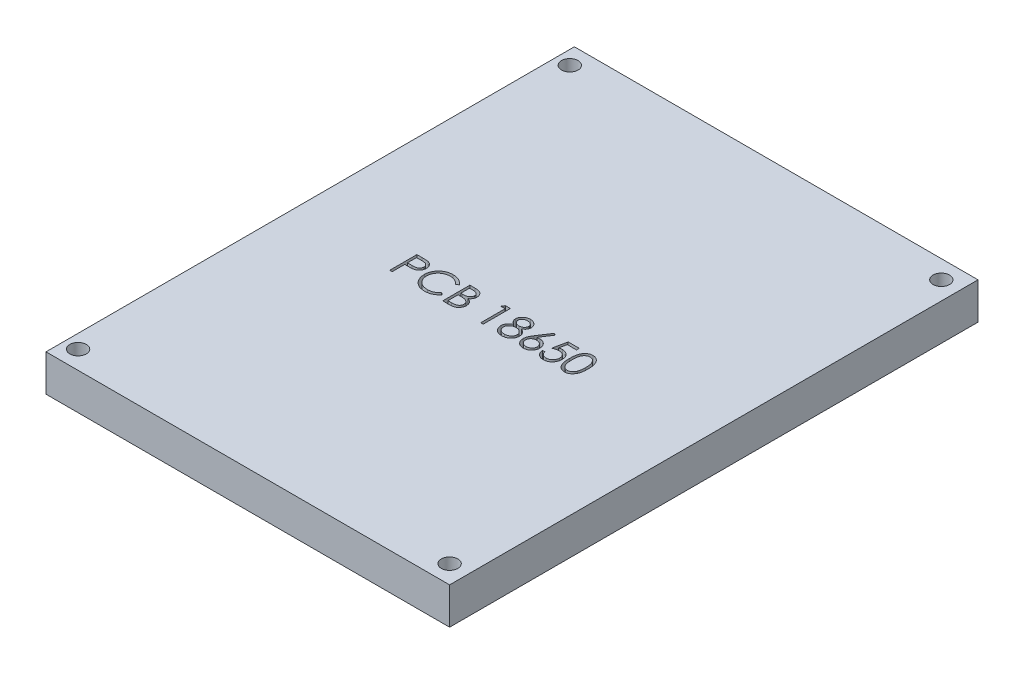
from build123d import *

# Parameters (mm, degrees)
CROQUIS1_W              = 110
CROQUIS1_H              = 144
SALIENTE_EXTRUIR1_DEPTH = 10
CORTAR_EXTRUIR1_DEPTH   = 3
CROQUIS3_R              = 2.25
CORTAR_EXTRUIR2_DEPTH   = 10


with BuildPart() as part:
    # Croquis1 → Saliente-Extruir1 (new body)
    with BuildSketch(Plane(origin=(0, 0, 0), x_dir=(1, 0, 0), z_dir=(0, 1, 0))):
        with Locations((-8.912037037, -15.981481481)):
            Rectangle(CROQUIS1_W, CROQUIS1_H)
    extrude(amount=SALIENTE_EXTRUIR1_DEPTH)

    # Croquis2 → Cortar-Extruir1 (cut)
    with BuildSketch(Plane(origin=(0, 10, 0), x_dir=(1, 0, 0), z_dir=(0, 1, 0))):
        with BuildLine():
            Line((-36.322498936, -14.485321481), (-34.869622667, -14.485321481))
            add(Edge.make_bspline(
                [(-34.869622667, -14.485321481), (-34.769692916, -14.485431328), (-34.578223074, -14.4856418), (-34.30365954, -14.492023012), (-34.054295608, -14.500546177), (-33.830668968, -14.512361184), (-33.632091561, -14.526323967), (-33.459461943, -14.54590745), (-33.311423216, -14.566355076), (-33.222721231, -14.587143719), (-33.1822679, -14.596624566)],
                knots=[0, 0, 0, 0, 0.00029978, 0.000574392, 0.00082387, 0.001048274, 0.001246209, 0.00142091, 0.001569507, 0.001694096, 0.001694096, 0.001694096, 0.001694096], degree=3))
            add(Edge.make_bspline(
                [(-33.1822679, -14.596624566), (-33.131058253, -14.610641026), (-33.029845651, -14.638343667), (-32.88400511, -14.693829382), (-32.745249471, -14.759619965), (-32.613102672, -14.834600637), (-32.489188596, -14.921988415), (-32.371658476, -15.018240906), (-32.261549518, -15.125580392), (-32.159480905, -15.242802958), (-32.06574475, -15.367940736), (-31.985036922, -15.502861789), (-31.917457624, -15.645295048), (-31.859496366, -15.795141441), (-31.817780138, -15.953659292), (-31.7863542, -16.119747166), (-31.766407522, -16.293387261), (-31.764497099, -16.412047314), (-31.763524577, -16.472452557)],
                knots=[0, 0, 0, 0, 0.000159208, 0.000314664, 0.000467348, 0.000619576, 0.000769845, 0.000921668, 0.001074891, 0.001230553, 0.001387567, 0.001543328, 0.001701307, 0.001860064, 0.002024586, 0.002192236, 0.002366938, 0.002548088, 0.002548088, 0.002548088, 0.002548088], degree=3))
            add(Edge.make_bspline(
                [(-31.763524577, -16.472452557), (-31.764416593, -16.533365518), (-31.766161882, -16.65254584), (-31.787109019, -16.826901575), (-31.815324591, -16.993522168), (-31.858710019, -17.152038171), (-31.91553336, -17.301508219), (-31.982191538, -17.444216493), (-32.062590011, -17.577735132), (-32.154971567, -17.702548864), (-32.257739109, -17.818774845), (-32.370457828, -17.925570827), (-32.492672664, -18.022311676), (-32.62399521, -18.109214271), (-32.765705724, -18.184263395), (-32.915654949, -18.251483024), (-33.07514624, -18.307936769), (-33.185514562, -18.337633733), (-33.241629545, -18.352732672)],
                knots=[0, 0, 0, 0, 0.000182634, 0.000357335, 0.000526177, 0.000689266, 0.000849412, 0.001005413, 0.001161174, 0.001316112, 0.001470659, 0.001626023, 0.00178131, 0.001937719, 0.002097735, 0.002261827, 0.002430336, 0.002604627, 0.002604627, 0.002604627, 0.002604627], degree=3))
            add(Edge.make_bspline(
                [(-33.241629545, -18.352732672), (-33.288042402, -18.362602649), (-33.389758876, -18.384233276), (-33.557277638, -18.408381177), (-33.752318705, -18.428992431), (-33.974615864, -18.444446506), (-34.22396958, -18.457676453), (-34.500514741, -18.468192251), (-34.804794205, -18.473970442), (-35.017035005, -18.474268453), (-35.127845824, -18.474424045)],
                knots=[0, 0, 0, 0, 0.000142321, 0.000311905, 0.000507421, 0.000730625, 0.000980302, 0.001256529, 0.001560815, 0.001893243, 0.001893243, 0.001893243, 0.001893243], degree=3))
            Line((-35.127845824, -18.474424045), (-35.657648509, -18.474424045))
            Line((-35.657648509, -18.474424045), (-35.657648509, -21.893654814))
            Line((-35.657648509, -21.893654814), (-36.322498936, -21.893654814))
            Line((-36.322498936, -21.893654814), (-36.322498936, -14.485321481))
        make_face()
        with BuildLine():
            Line((-35.657648509, -15.245150541), (-35.657648509, -17.714594985))
            Line((-35.657648509, -17.714594985), (-34.360596559, -17.730919438))
            add(Edge.make_bspline(
                [(-34.360596559, -17.730919438), (-34.297266049, -17.730952169), (-34.175007806, -17.731015356), (-33.998401134, -17.722579966), (-33.834551475, -17.712842172), (-33.683962124, -17.698584467), (-33.546565196, -17.678431139), (-33.422131593, -17.658086294), (-33.311626178, -17.628653276), (-33.182299534, -17.58902278), (-33.038189782, -17.521432077), (-32.881413471, -17.42332481), (-32.748549063, -17.298270644), (-32.633575335, -17.157665068), (-32.54233456, -17.001245244), (-32.475541043, -16.833882661), (-32.436295593, -16.657293713), (-32.43103315, -16.536457152), (-32.428375004, -16.47542064)],
                knots=[0, 0, 0, 0, 0.000189963, 0.00036672, 0.000530295, 0.000682392, 0.000820281, 0.000946912, 0.001060293, 0.001163078, 0.001352344, 0.00153594, 0.001715534, 0.001897012, 0.002079253, 0.002256452, 0.002435769, 0.002618794, 0.002618794, 0.002618794, 0.002618794], degree=3))
            add(Edge.make_bspline(
                [(-32.428375004, -16.47542064), (-32.431047606, -16.415860786), (-32.436360408, -16.297463169), (-32.475848651, -16.123941459), (-32.542204699, -15.958342551), (-32.634187824, -15.803882854), (-32.745823216, -15.663783219), (-32.875573492, -15.542080967), (-33.023133229, -15.444245029), (-33.160395318, -15.381097916), (-33.282317828, -15.34254225), (-33.38821881, -15.315565671), (-33.507790737, -15.294027304), (-33.641072537, -15.276587024), (-33.787031169, -15.261657197), (-33.946920602, -15.251526879), (-34.120135147, -15.24559713), (-34.240384189, -15.245303008), (-34.302718955, -15.245150541)],
                knots=[0, 0, 0, 0, 0.000178585, 0.000355005, 0.000530825, 0.000711787, 0.000892334, 0.001066644, 0.00124322, 0.001421188, 0.001517867, 0.001626567, 0.001748818, 0.001882093, 0.002029761, 0.002188893, 0.002362627, 0.002549622, 0.002549622, 0.002549622, 0.002549622], degree=3))
            Line((-34.302718955, -15.245150541), (-35.657648509, -15.245150541))
        make_face(mode=Mode.SUBTRACT)
        with BuildLine():
            Line((-23.405404919, -15.844703158), (-23.987149043, -16.289915498))
            add(Edge.make_bspline(
                [(-23.987149043, -16.289915498), (-24.028648173, -16.240457529), (-24.111086936, -16.14220839), (-24.243715581, -16.004245021), (-24.381937392, -15.874990218), (-24.525699532, -15.753828239), (-24.677589668, -15.644996085), (-24.833928358, -15.542822251), (-24.997330887, -15.451238872), (-25.223288726, -15.340192218), (-25.518876671, -15.224312856), (-25.890975747, -15.127151017), (-26.279407572, -15.065299528), (-26.544409158, -15.058600614), (-26.679199657, -15.055193276)],
                knots=[0, 0, 0, 0, 0.000193643, 0.000384676, 0.000573668, 0.00076121, 0.000948223, 0.00113387, 0.00132126, 0.00150975, 0.00188896, 0.002271247, 0.002661637, 0.003065757, 0.003065757, 0.003065757, 0.003065757], degree=3))
            add(Edge.make_bspline(
                [(-26.679199657, -15.055193276), (-26.753459307, -15.05604833), (-26.901289408, -15.057750502), (-27.120678677, -15.080206484), (-27.335971302, -15.111768545), (-27.547027239, -15.158600479), (-27.753577835, -15.217809189), (-27.956973419, -15.288559649), (-28.154269189, -15.37609406), (-28.348194459, -15.47284321), (-28.533993789, -15.582121302), (-28.70979364, -15.701317896), (-28.874952839, -15.829099151), (-29.029602035, -15.965943992), (-29.173899326, -16.111236142), (-29.306799133, -16.266523998), (-29.427841585, -16.431311099), (-29.539425955, -16.603424478), (-29.639359574, -16.782362804), (-29.723031152, -16.96878837), (-29.797125327, -17.159508721), (-29.855755391, -17.356678678), (-29.902162285, -17.558910866), (-29.934182505, -17.766748034), (-29.956383103, -17.979755989), (-29.95807681, -18.124132367), (-29.95893056, -18.196908353)],
                knots=[0, 0, 0, 0, 0.000222685, 0.000443304, 0.000660953, 0.0008752, 0.00109128, 0.001305311, 0.00152064, 0.001738329, 0.001955182, 0.002166751, 0.002375136, 0.002581198, 0.002785829, 0.002988969, 0.003193773, 0.003398769, 0.003604029, 0.00380791, 0.00401131, 0.004217421, 0.004424428, 0.004633277, 0.004847987, 0.005066222, 0.005066222, 0.005066222, 0.005066222], degree=3))
            add(Edge.make_bspline(
                [(-29.95893056, -18.196908353), (-29.95625971, -18.306406314), (-29.951015849, -18.521391035), (-29.904346876, -18.836288827), (-29.833427766, -19.137957587), (-29.727138128, -19.424511586), (-29.596076138, -19.699484278), (-29.430466843, -19.958223184), (-29.238661839, -20.204638246), (-29.017947651, -20.432905818), (-28.775788674, -20.641426537), (-28.515972261, -20.825048601), (-28.239145519, -20.978115102), (-27.948364985, -21.105487522), (-27.641393044, -21.203397596), (-27.318781712, -21.272324991), (-26.981232655, -21.317287606), (-26.750580759, -21.321592246), (-26.633194382, -21.323783019)],
                knots=[0, 0, 0, 0, 0.000328309, 0.000644591, 0.000953061, 0.001256343, 0.001559672, 0.001865168, 0.002175989, 0.002495062, 0.00281603, 0.003133469, 0.0034477, 0.003763386, 0.004084406, 0.00441246, 0.004752075, 0.005104046, 0.005104046, 0.005104046, 0.005104046], degree=3))
            add(Edge.make_bspline(
                [(-26.633194382, -21.323783019), (-26.503860357, -21.320208436), (-26.249300056, -21.3131728), (-25.875987734, -21.253569056), (-25.518618697, -21.156926463), (-25.177173722, -21.021675861), (-24.852615387, -20.845854334), (-24.54443579, -20.632710494), (-24.252374799, -20.380216856), (-24.076752252, -20.187424235), (-23.987149043, -20.089060797)],
                knots=[0, 0, 0, 0, 0.000387815, 0.000763313, 0.001130882, 0.001496577, 0.00186244, 0.002235811, 0.002618757, 0.003017658, 0.003017658, 0.003017658, 0.003017658], degree=3))
            Line((-23.987149043, -20.089060797), (-23.405404919, -20.529821013))
            add(Edge.make_bspline(
                [(-23.405404919, -20.529821013), (-23.452221585, -20.590227403), (-23.545630667, -20.71075084), (-23.69688347, -20.880659292), (-23.856220416, -21.040476167), (-24.024825002, -21.188912966), (-24.200757661, -21.328939918), (-24.387177389, -21.456578794), (-24.581633508, -21.573611166), (-24.783467155, -21.680771489), (-24.992463885, -21.775846329), (-25.208373273, -21.857240137), (-25.430264657, -21.927354487), (-25.658148184, -21.985037753), (-25.892496536, -22.030061547), (-26.132464039, -22.060159859), (-26.378568608, -22.080780244), (-26.54460295, -22.082659666), (-26.628742259, -22.083612079)],
                knots=[0, 0, 0, 0, 0.000229221, 0.000457343, 0.00068191, 0.000905843, 0.001130894, 0.001356063, 0.001583087, 0.001811456, 0.002041252, 0.002271398, 0.002503261, 0.002739018, 0.002976228, 0.003218654, 0.003464279, 0.003716636, 0.003716636, 0.003716636, 0.003716636], degree=3))
            add(Edge.make_bspline(
                [(-26.628742259, -22.083612079), (-26.708421354, -22.083057528), (-26.865976898, -22.081960973), (-27.098595922, -22.064197552), (-27.325057202, -22.039962275), (-27.544713493, -22.003470664), (-27.758763473, -21.960408478), (-27.965266711, -21.902684318), (-28.166255239, -21.838021915), (-28.36092156, -21.762023027), (-28.549431258, -21.676263774), (-28.731176326, -21.579338307), (-28.906073174, -21.472061694), (-29.075841315, -21.356798588), (-29.237972867, -21.229846633), (-29.393872829, -21.092968923), (-29.544415404, -20.9466268), (-29.63755442, -20.841100694), (-29.68438295, -20.788044171)],
                knots=[0, 0, 0, 0, 0.000238972, 0.000472538, 0.000699518, 0.000922026, 0.001140316, 0.001354167, 0.001564885, 0.001773508, 0.001980706, 0.002185853, 0.002390994, 0.002595985, 0.002801116, 0.003008293, 0.003218178, 0.003430412, 0.003430412, 0.003430412, 0.003430412], degree=3))
            add(Edge.make_bspline(
                [(-29.68438295, -20.788044171), (-29.759388396, -20.695881987), (-29.908493755, -20.512670284), (-30.099259785, -20.215731623), (-30.262555444, -19.905707248), (-30.394584476, -19.580968399), (-30.497798928, -19.242243762), (-30.569302458, -18.88936259), (-30.615766687, -18.522654446), (-30.621080132, -18.273233243), (-30.623780987, -18.146450955)],
                knots=[0, 0, 0, 0, 0.000356247, 0.000708193, 0.00105669, 0.001406134, 0.00175823, 0.002117387, 0.002485166, 0.00286537, 0.00286537, 0.00286537, 0.00286537], degree=3))
            add(Edge.make_bspline(
                [(-30.623780987, -18.146450955), (-30.620489161, -18.013195245), (-30.614012698, -17.751022954), (-30.558988264, -17.366268087), (-30.470471812, -16.997647626), (-30.344748398, -16.6458497), (-30.185352071, -16.30902394), (-29.988445739, -15.98974339), (-29.756316954, -15.685966164), (-29.490786269, -15.402301607), (-29.199602076, -15.142926644), (-28.887777254, -14.914736846), (-28.555922132, -14.72483477), (-28.20769268, -14.566092893), (-27.84048132, -14.444078779), (-27.455071522, -14.358664534), (-27.052187486, -14.305499971), (-26.777312019, -14.298779115), (-26.637646505, -14.295364216)],
                knots=[0, 0, 0, 0, 0.000399604, 0.000786196, 0.001163414, 0.001535172, 0.001904915, 0.00227932, 0.002658359, 0.003050013, 0.003443158, 0.003826676, 0.004206973, 0.004588207, 0.004973029, 0.005365467, 0.005770983, 0.006189861, 0.006189861, 0.006189861, 0.006189861], degree=3))
            add(Edge.make_bspline(
                [(-26.637646505, -14.295364216), (-26.552525873, -14.296384742), (-26.384038154, -14.29840477), (-26.13479504, -14.318102771), (-25.892135448, -14.350939904), (-25.655892202, -14.395635585), (-25.424915998, -14.451107749), (-25.200972155, -14.52337138), (-24.982746601, -14.605998705), (-24.771615645, -14.701160791), (-24.568592281, -14.80798206), (-24.37373974, -14.925278464), (-24.188605789, -15.052904585), (-24.011887726, -15.189774973), (-23.846541746, -15.338785257), (-23.687873283, -15.495836835), (-23.541270668, -15.66545343), (-23.450776405, -15.784843873), (-23.405404919, -15.844703158)],
                knots=[0, 0, 0, 0, 0.000255324, 0.000505388, 0.00074948, 0.000989606, 0.001226445, 0.001461584, 0.001695032, 0.001926181, 0.002155862, 0.002382886, 0.002608055, 0.002830107, 0.00305293, 0.003275398, 0.003499469, 0.003724774, 0.003724774, 0.003724774, 0.003724774], degree=3))
        make_face()
        with BuildLine():
            Line((-21.885746799, -14.485321481), (-20.440290736, -14.485321481))
            add(Edge.make_bspline(
                [(-20.440290736, -14.485321481), (-20.369533791, -14.485693486), (-20.23238922, -14.486414524), (-20.032958069, -14.497597152), (-19.846164753, -14.51284492), (-19.671955101, -14.537038616), (-19.510409615, -14.566231211), (-19.361041449, -14.601583388), (-19.224325584, -14.643973054), (-19.061103626, -14.711381016), (-18.875004894, -14.811548389), (-18.673501629, -14.959563852), (-18.501195989, -15.140607565), (-18.352634951, -15.344829186), (-18.234522581, -15.569483236), (-18.149074235, -15.809215186), (-18.094976732, -16.060932873), (-18.089413213, -16.233744266), (-18.0866015, -16.321080362)],
                knots=[0, 0, 0, 0, 0.000212239, 0.000411371, 0.000599072, 0.000774321, 0.000938782, 0.0010914, 0.001234554, 0.001367664, 0.001620652, 0.001866708, 0.002114396, 0.002367311, 0.002622221, 0.002872887, 0.003129012, 0.003390713, 0.003390713, 0.003390713, 0.003390713], degree=3))
            add(Edge.make_bspline(
                [(-18.0866015, -16.321080362), (-18.088915479, -16.402894938), (-18.093462666, -16.563668296), (-18.13694484, -16.798817494), (-18.205018255, -17.022657573), (-18.299644366, -17.234371623), (-18.422626924, -17.429176104), (-18.568377032, -17.608642484), (-18.744222931, -17.765172221), (-18.875971122, -17.852681365), (-18.942893234, -17.897132044)],
                knots=[0, 0, 0, 0, 0.000245231, 0.000481902, 0.00071474, 0.000945889, 0.001175244, 0.001404022, 0.001637324, 0.001878168, 0.001878168, 0.001878168, 0.001878168], degree=3))
            add(Edge.make_bspline(
                [(-18.942893234, -17.897132044), (-18.858733662, -17.929442959), (-18.697715553, -17.991261742), (-18.47613016, -18.100556808), (-18.285217738, -18.219433275), (-18.123510446, -18.349252357), (-17.98521241, -18.489182674), (-17.86445035, -18.641275999), (-17.761408108, -18.80751637), (-17.673115753, -18.986170519), (-17.604220886, -19.175414211), (-17.552625222, -19.373472354), (-17.523060788, -19.579634745), (-17.518853614, -19.719938798), (-17.516729705, -19.79076853)],
                knots=[0, 0, 0, 0, 0.000270344, 0.000517235, 0.000739985, 0.00094371, 0.001137847, 0.001329058, 0.001525064, 0.00172351, 0.001925868, 0.002128155, 0.002336561, 0.002549033, 0.002549033, 0.002549033, 0.002549033], degree=3))
            add(Edge.make_bspline(
                [(-17.516729705, -19.79076853), (-17.518797363, -19.863088409), (-17.522865537, -20.005379797), (-17.55287981, -20.214411499), (-17.603699087, -20.414171803), (-17.67369968, -20.605952773), (-17.765059912, -20.789383391), (-17.876244103, -20.964671466), (-18.008814246, -21.130055799), (-18.157113986, -21.287374135), (-18.324885527, -21.428826285), (-18.505893875, -21.554801197), (-18.702418585, -21.658403695), (-18.911231973, -21.745432607), (-19.134676442, -21.811911178), (-19.371748627, -21.858419792), (-19.622244066, -21.889757121), (-19.79413804, -21.892333538), (-19.88229127, -21.893654814)],
                knots=[0, 0, 0, 0, 0.000216919, 0.000426794, 0.000631957, 0.000834315, 0.001038067, 0.001245562, 0.001455778, 0.001673062, 0.001893106, 0.002112925, 0.002333348, 0.002558238, 0.002790646, 0.00303134, 0.003282419, 0.003546729, 0.003546729, 0.003546729, 0.003546729], degree=3))
            Line((-19.88229127, -21.893654814), (-21.885746799, -21.893654814))
            Line((-21.885746799, -21.893654814), (-21.885746799, -14.485321481))
        make_face()
        with BuildLine():
            Line((-21.220896372, -15.245150541), (-21.220896372, -17.619616353))
            Line((-21.220896372, -17.619616353), (-20.774199991, -17.619616353))
            add(Edge.make_bspline(
                [(-20.774199991, -17.619616353), (-20.708903374, -17.618769849), (-20.582737004, -17.617134231), (-20.400026556, -17.612448954), (-20.230428601, -17.599329762), (-20.074235887, -17.58621434), (-19.931694381, -17.564889796), (-19.803119874, -17.53950647), (-19.686494511, -17.512660987), (-19.552002473, -17.467005573), (-19.399448065, -17.399531161), (-19.236817995, -17.294815774), (-19.093446701, -17.17009256), (-18.97237932, -17.026178358), (-18.873295041, -16.867711598), (-18.804474344, -16.697220701), (-18.757807592, -16.518954754), (-18.753592184, -16.396572786), (-18.751451927, -16.334436732)],
                knots=[0, 0, 0, 0, 0.000195916, 0.000378549, 0.000548146, 0.000706153, 0.00084866, 0.000980213, 0.001099353, 0.001207291, 0.001405892, 0.001598137, 0.00178535, 0.001973846, 0.002160417, 0.002343412, 0.00252374, 0.002709725, 0.002709725, 0.002709725, 0.002709725], degree=3))
            add(Edge.make_bspline(
                [(-18.751451927, -16.334436732), (-18.752565675, -16.293318849), (-18.754750414, -16.212661631), (-18.772643238, -16.095082165), (-18.803054604, -15.984499556), (-18.842116191, -15.879398355), (-18.896702249, -15.783064939), (-18.960971579, -15.692168508), (-19.038622957, -15.609804524), (-19.127009269, -15.532822419), (-19.228627521, -15.464571502), (-19.343417088, -15.40479522), (-19.472931005, -15.356660576), (-19.614986548, -15.31450472), (-19.77177035, -15.284896165), (-19.941473155, -15.260229828), (-20.125484976, -15.24767219), (-20.25279211, -15.246009839), (-20.318599363, -15.245150541)],
                knots=[0, 0, 0, 0, 0.000123318, 0.000241902, 0.000355662, 0.000467004, 0.000577274, 0.000686822, 0.000800232, 0.000915968, 0.001037804, 0.001166574, 0.001303275, 0.001451679, 0.00161059, 0.001781428, 0.001965934, 0.002163361, 0.002163361, 0.002163361, 0.002163361], degree=3))
            Line((-20.318599363, -15.245150541), (-21.220896372, -15.245150541))
        make_face(mode=Mode.SUBTRACT)
        with BuildLine():
            Line((-21.220896372, -18.379445413), (-21.220896372, -21.133825754))
            Line((-21.220896372, -21.133825754), (-20.274078129, -21.133825754))
            add(Edge.make_bspline(
                [(-20.274078129, -21.133825754), (-20.206304736, -21.133013489), (-20.075680456, -21.131447955), (-19.887082852, -21.126337148), (-19.712281949, -21.114711831), (-19.552075395, -21.096411449), (-19.40473327, -21.076560398), (-19.272023132, -21.04986652), (-19.152869206, -21.019282887), (-19.014705254, -20.972008889), (-18.859122829, -20.898568026), (-18.691459849, -20.787836247), (-18.542391021, -20.655918578), (-18.415803222, -20.503241477), (-18.312059063, -20.337228501), (-18.23658835, -20.161237511), (-18.190041036, -19.978176478), (-18.184406111, -19.853363603), (-18.181580133, -19.79076853)],
                knots=[0, 0, 0, 0, 0.000203335, 0.000391902, 0.00056594, 0.000728678, 0.000875591, 0.001011799, 0.001134545, 0.001244364, 0.001449495, 0.00164871, 0.001845283, 0.002044415, 0.002241681, 0.002430505, 0.002616951, 0.002804529, 0.002804529, 0.002804529, 0.002804529], degree=3))
            add(Edge.make_bspline(
                [(-18.181580133, -19.79076853), (-18.182164553, -19.751624292), (-18.183323968, -19.673967217), (-18.200808937, -19.5598454), (-18.226238294, -19.449300635), (-18.259113163, -19.342032751), (-18.306991035, -19.239981104), (-18.362884888, -19.141127353), (-18.428419855, -19.045340822), (-18.530536673, -18.924241552), (-18.679067373, -18.784717208), (-18.890113382, -18.648112828), (-19.130084746, -18.53794497), (-19.304132939, -18.491167745), (-19.394041738, -18.467003839)],
                knots=[0, 0, 0, 0, 0.000117324, 0.000232755, 0.000345435, 0.000457605, 0.000568512, 0.000682821, 0.000798081, 0.000916078, 0.001157581, 0.001406192, 0.001667185, 0.001946074, 0.001946074, 0.001946074, 0.001946074], degree=3))
            add(Edge.make_bspline(
                [(-19.394041738, -18.467003839), (-19.430086657, -18.459690578), (-19.508239478, -18.44383392), (-19.635678856, -18.427095948), (-19.781169779, -18.412183904), (-19.945048202, -18.401153621), (-20.127521466, -18.389752103), (-20.328979277, -18.385318065), (-20.548598927, -18.380027965), (-20.700982782, -18.379644564), (-20.780136156, -18.379445413)],
                knots=[0, 0, 0, 0, 0.000110309, 0.000239173, 0.000385365, 0.00054904, 0.000731873, 0.000933789, 0.001153473, 0.001390924, 0.001390924, 0.001390924, 0.001390924], degree=3))
            Line((-20.780136156, -18.379445413), (-21.220896372, -18.379445413))
        make_face(mode=Mode.SUBTRACT)
        Polygon((-12.237995397, -14.485321481), (-10.868225432, -14.485321481), (-10.868225432, -21.893654814), (-11.533075859, -21.893654814), (-11.533075859, -15.245150541), (-12.672819449, -15.245150541), align=None)
        with BuildLine():
            add(Edge.make_bspline(
                [(-4.512077261, -17.766536425), (-4.451437837, -17.798155098), (-4.333170707, -17.859822071), (-4.164732283, -17.959116656), (-4.010797697, -18.063766699), (-3.867096007, -18.168829268), (-3.736151915, -18.27832793), (-3.619429574, -18.39269811), (-3.514045779, -18.509085028), (-3.422125753, -18.629459523), (-3.341275782, -18.753501797), (-3.271400096, -18.881537425), (-3.211673683, -19.013285815), (-3.164338796, -19.150185105), (-3.125346003, -19.290224325), (-3.098515973, -19.43521172), (-3.08408683, -19.584191908), (-3.081358842, -19.684878147), (-3.079977568, -19.735859008)],
                knots=[0, 0, 0, 0, 0.000205147, 0.000400105, 0.000586149, 0.000763348, 0.00093398, 0.001097696, 0.001253231, 0.00140461, 0.00155156, 0.001697004, 0.00184181, 0.001984964, 0.002131133, 0.002277542, 0.002426687, 0.002579658, 0.002579658, 0.002579658, 0.002579658], degree=3))
            add(Edge.make_bspline(
                [(-3.079977568, -19.735859008), (-3.081610409, -19.807185875), (-3.084842412, -19.948368509), (-3.112994045, -20.156746111), (-3.155143183, -20.359124383), (-3.216694817, -20.555458955), (-3.296521494, -20.744666462), (-3.394897464, -20.926908866), (-3.506257848, -21.10517307), (-3.595691754, -21.21485747), (-3.640945117, -21.270357539)],
                knots=[0, 0, 0, 0, 0.000213887, 0.000423363, 0.00062973, 0.000833439, 0.001039609, 0.001244756, 0.0014543, 0.001668932, 0.001668932, 0.001668932, 0.001668932], degree=3))
            add(Edge.make_bspline(
                [(-3.640945117, -21.270357539), (-3.699865654, -21.335114361), (-3.816978631, -21.463827787), (-4.017602494, -21.630940335), (-4.237782148, -21.771379885), (-4.476665619, -21.885832062), (-4.733614351, -21.974913797), (-5.008573594, -22.038927126), (-5.302079384, -22.075592935), (-5.503809298, -22.080893046), (-5.607299617, -22.083612079)],
                knots=[0, 0, 0, 0, 0.000262419, 0.000521596, 0.000780539, 0.001044051, 0.001314391, 0.001594812, 0.001889513, 0.002199965, 0.002199965, 0.002199965, 0.002199965], degree=3))
            add(Edge.make_bspline(
                [(-5.607299617, -22.083612079), (-5.70681129, -22.081172668), (-5.900450897, -22.07642582), (-6.182301738, -22.044264273), (-6.445028902, -21.987901956), (-6.690160002, -21.910760866), (-6.916217236, -21.810409216), (-7.122556467, -21.685508084), (-7.312154708, -21.541084865), (-7.479258077, -21.372991733), (-7.62761195, -21.19295257), (-7.757930996, -21.007211662), (-7.866249462, -20.815752055), (-7.95795848, -20.621428578), (-8.028164128, -20.421517552), (-8.07678864, -20.217047524), (-8.107669355, -20.008375638), (-8.11177809, -19.867550306), (-8.11384509, -19.796704694)],
                knots=[0, 0, 0, 0, 0.000298528, 0.000580906, 0.000849567, 0.001103477, 0.001350595, 0.001589581, 0.001825562, 0.002063773, 0.002298819, 0.002524832, 0.00274351, 0.002957963, 0.003168702, 0.003377831, 0.003587706, 0.003800178, 0.003800178, 0.003800178, 0.003800178], degree=3))
            add(Edge.make_bspline(
                [(-8.11384509, -19.796704694), (-8.112621908, -19.744721071), (-8.11020447, -19.641983083), (-8.093472541, -19.490198339), (-8.066572965, -19.342463187), (-8.030040448, -19.198231946), (-7.980529442, -19.058554652), (-7.92075026, -18.922769483), (-7.851044294, -18.79072314), (-7.770439161, -18.661693509), (-7.676666544, -18.537488541), (-7.570486818, -18.416000353), (-7.44977783, -18.299114067), (-7.315882452, -18.185401601), (-7.170330843, -18.07284579), (-7.009342404, -17.967529498), (-6.83718487, -17.861996805), (-6.714830095, -17.798902517), (-6.652064574, -17.766536425)],
                knots=[0, 0, 0, 0, 0.000155937, 0.000308187, 0.000457516, 0.000606172, 0.000754019, 0.000901537, 0.001050903, 0.001201604, 0.001357429, 0.001517278, 0.001685192, 0.001860968, 0.002044107, 0.002236735, 0.0024378, 0.002649581, 0.002649581, 0.002649581, 0.002649581], degree=3))
            add(Edge.make_bspline(
                [(-6.652064574, -17.766536425), (-6.737982984, -17.719684498), (-6.904345074, -17.628966054), (-7.124625391, -17.462285314), (-7.313835544, -17.281759439), (-7.466774696, -17.083576374), (-7.587154246, -16.873927156), (-7.669743625, -16.654123489), (-7.725616183, -16.428241049), (-7.7311509, -16.273922932), (-7.73393056, -16.196420907)],
                knots=[0, 0, 0, 0, 0.000293232, 0.00056778, 0.000825961, 0.001075606, 0.00131619, 0.001548252, 0.001778283, 0.002010368, 0.002010368, 0.002010368, 0.002010368], degree=3))
            add(Edge.make_bspline(
                [(-7.73393056, -16.196420907), (-7.730468912, -16.117474408), (-7.723510397, -15.958778178), (-7.667242368, -15.722545217), (-7.575548227, -15.490523488), (-7.450832117, -15.263837562), (-7.295495843, -15.050159608), (-7.109130654, -14.858514605), (-6.896187009, -14.690638634), (-6.657727857, -14.549719068), (-6.401111158, -14.435030323), (-6.13035621, -14.355912662), (-5.850180466, -14.304189548), (-5.659473626, -14.298333463), (-5.562778383, -14.295364216)],
                knots=[0, 0, 0, 0, 0.000236634, 0.000475675, 0.000724255, 0.000983283, 0.001249837, 0.001514313, 0.001782707, 0.002060888, 0.002343266, 0.002623577, 0.002905381, 0.003195229, 0.003195229, 0.003195229, 0.003195229], degree=3))
            add(Edge.make_bspline(
                [(-5.562778383, -14.295364216), (-5.468578641, -14.298425642), (-5.282827482, -14.304462426), (-5.009788854, -14.354811318), (-4.74853953, -14.438905468), (-4.499980424, -14.552987924), (-4.268561304, -14.693506949), (-4.064086416, -14.863688799), (-3.883465785, -15.054488415), (-3.73406215, -15.268101575), (-3.610950701, -15.493916451), (-3.525223793, -15.730184121), (-3.470292115, -15.971799629), (-3.463363494, -16.135286737), (-3.459892098, -16.217197483)],
                knots=[0, 0, 0, 0, 0.00028244, 0.000556939, 0.00082962, 0.001103878, 0.001375713, 0.001639263, 0.001899644, 0.002161525, 0.002419138, 0.002668916, 0.002913427, 0.003158941, 0.003158941, 0.003158941, 0.003158941], degree=3))
            add(Edge.make_bspline(
                [(-3.459892098, -16.217197483), (-3.462928585, -16.297581421), (-3.468892072, -16.455450907), (-3.519056944, -16.685588709), (-3.603540125, -16.901112025), (-3.718886103, -17.10446644), (-3.869223385, -17.291963944), (-4.052545203, -17.465988805), (-4.267389999, -17.627970591), (-4.428808875, -17.719381729), (-4.512077261, -17.766536425)],
                knots=[0, 0, 0, 0, 0.000240968, 0.000473248, 0.000702541, 0.000933184, 0.001171907, 0.001420664, 0.00168987, 0.001976704, 0.001976704, 0.001976704, 0.001976704], degree=3))
        make_face()
        with BuildLine():
            add(Edge.make_bspline(
                [(-5.599879411, -15.055193276), (-5.651845284, -15.056572158), (-5.753513252, -15.059269855), (-5.902587273, -15.07336397), (-6.04434545, -15.100781613), (-6.180268895, -15.137270219), (-6.308494048, -15.186563127), (-6.430762355, -15.24454923), (-6.544992907, -15.315047068), (-6.652564665, -15.394128271), (-6.749403804, -15.481108255), (-6.835350105, -15.571730627), (-6.90674128, -15.667775207), (-6.967364962, -15.766852901), (-7.011352507, -15.871904288), (-7.04429695, -15.979708611), (-7.066567229, -16.091628174), (-7.068235988, -16.168117121), (-7.069080133, -16.206809195)],
                knots=[0, 0, 0, 0, 0.000155937, 0.000305082, 0.000448574, 0.000588625, 0.000726713, 0.000860128, 0.000994005, 0.001128759, 0.001260136, 0.001384033, 0.001502757, 0.00161856, 0.001731581, 0.001843308, 0.001956534, 0.002072441, 0.002072441, 0.002072441, 0.002072441], degree=3))
            add(Edge.make_bspline(
                [(-7.069080133, -16.206809195), (-7.067625206, -16.24550294), (-7.064750062, -16.321967339), (-7.042514208, -16.434882755), (-7.009373865, -16.545841886), (-6.957196632, -16.652206315), (-6.894614506, -16.757665758), (-6.817374215, -16.859584499), (-6.72532244, -16.95831723), (-6.621547691, -17.053024181), (-6.508493269, -17.141709896), (-6.388723711, -17.218699797), (-6.263742183, -17.283118664), (-6.134832803, -17.336732571), (-6.000681756, -17.378409605), (-5.862111054, -17.407976573), (-5.719097407, -17.426353466), (-5.622195178, -17.428548494), (-5.573166671, -17.429659088)],
                knots=[0, 0, 0, 0, 0.000115993, 0.000229218, 0.00034422, 0.000462385, 0.000583532, 0.000711754, 0.000845128, 0.000987982, 0.001132849, 0.001275695, 0.001414419, 0.001554148, 0.001694026, 0.001835197, 0.001978774, 0.002125814, 0.002125814, 0.002125814, 0.002125814], degree=3))
            add(Edge.make_bspline(
                [(-5.573166671, -17.429659088), (-5.510195618, -17.427811519), (-5.384875473, -17.42413463), (-5.200134221, -17.389947979), (-5.020508291, -17.33617212), (-4.84791761, -17.262596857), (-4.686829571, -17.170251221), (-4.54323476, -17.059691332), (-4.418358003, -16.93347006), (-4.313497045, -16.793552391), (-4.232196203, -16.644641529), (-4.168904044, -16.495204243), (-4.131944471, -16.343646187), (-4.127123621, -16.242116114), (-4.124742526, -16.191968783)],
                knots=[0, 0, 0, 0, 0.000188759, 0.000375654, 0.00056158, 0.000750404, 0.00093724, 0.001117121, 0.00129237, 0.001468378, 0.001639764, 0.001800157, 0.001954219, 0.002104576, 0.002104576, 0.002104576, 0.002104576], degree=3))
            add(Edge.make_bspline(
                [(-4.124742526, -16.191968783), (-4.125868376, -16.156772774), (-4.128103026, -16.08691374), (-4.146518145, -15.983750867), (-4.176946991, -15.882934915), (-4.218143844, -15.783633042), (-4.272351243, -15.687238492), (-4.336622106, -15.592235956), (-4.414694301, -15.500762589), (-4.502316752, -15.410686678), (-4.601684533, -15.327323828), (-4.712606148, -15.254013692), (-4.834512919, -15.191757537), (-4.96740773, -15.141193006), (-5.110801153, -15.103215033), (-5.264032737, -15.074774763), (-5.42838015, -15.058745011), (-5.541473123, -15.056402865), (-5.599879411, -15.055193276)],
                knots=[0, 0, 0, 0, 0.000105534, 0.00020947, 0.000313236, 0.000421, 0.00053127, 0.000644466, 0.000764554, 0.000891533, 0.001021121, 0.001152834, 0.001289559, 0.001430948, 0.001578549, 0.001733984, 0.001898043, 0.00207326, 0.00207326, 0.00207326, 0.00207326], degree=3))
        make_face(mode=Mode.SUBTRACT)
        with BuildLine():
            add(Edge.make_bspline(
                [(-5.556842219, -18.189488148), (-5.622725131, -18.190660022), (-5.751971331, -18.192958953), (-5.941321828, -18.218548396), (-6.123044362, -18.254170611), (-6.296526228, -18.308210886), (-6.461694166, -18.37847679), (-6.619442311, -18.4630049), (-6.768563868, -18.562923088), (-6.906999639, -18.676961924), (-7.03341402, -18.799854435), (-7.144323755, -18.929949288), (-7.238510173, -19.064828649), (-7.314357221, -19.206205534), (-7.376612053, -19.35108631), (-7.417493094, -19.503079054), (-7.44370105, -19.659261776), (-7.447220287, -19.765433985), (-7.448994662, -19.818965311)],
                knots=[0, 0, 0, 0, 0.000197517, 0.00038748, 0.000572295, 0.000752544, 0.000931431, 0.00111004, 0.001288675, 0.001469003, 0.001647409, 0.001816908, 0.001981161, 0.002139871, 0.002297521, 0.002453063, 0.002610916, 0.00277144, 0.00277144, 0.00277144, 0.00277144], degree=3))
            add(Edge.make_bspline(
                [(-7.448994662, -19.818965311), (-7.446109098, -19.885494062), (-7.440384206, -20.01748555), (-7.394967654, -20.212564051), (-7.322079103, -20.401415284), (-7.22042573, -20.582500251), (-7.094552701, -20.751727976), (-6.939768344, -20.899235884), (-6.765691904, -21.030303014), (-6.566433446, -21.136306809), (-6.34877986, -21.220962586), (-6.112789034, -21.279289374), (-5.861847789, -21.317900443), (-5.688578319, -21.321791259), (-5.599879411, -21.323783019)],
                knots=[0, 0, 0, 0, 0.000199414, 0.000395634, 0.000597649, 0.000804926, 0.001016848, 0.001227796, 0.001444171, 0.001668615, 0.001902595, 0.002143033, 0.002396565, 0.002662473, 0.002662473, 0.002662473, 0.002662473], degree=3))
            add(Edge.make_bspline(
                [(-5.599879411, -21.323783019), (-5.530557799, -21.322452042), (-5.395497069, -21.31985887), (-5.198465144, -21.296968614), (-5.012527516, -21.260668575), (-4.838044759, -21.207871403), (-4.673063632, -21.143418952), (-4.520381366, -21.060504713), (-4.37607015, -20.966202296), (-4.24724109, -20.854319198), (-4.129907465, -20.734770934), (-4.027601996, -20.608215343), (-3.938791846, -20.478091921), (-3.86908799, -20.341460062), (-3.813364086, -20.200941093), (-3.773309228, -20.055239261), (-3.748594573, -19.903907684), (-3.74609501, -19.801251317), (-3.744827996, -19.749215378)],
                knots=[0, 0, 0, 0, 0.000207898, 0.000405052, 0.000594231, 0.000775467, 0.000951286, 0.00112457, 0.001295795, 0.001467387, 0.0016353, 0.001797773, 0.001955005, 0.002107001, 0.002256919, 0.002407774, 0.002559531, 0.002715532, 0.002715532, 0.002715532, 0.002715532], degree=3))
            add(Edge.make_bspline(
                [(-3.744827996, -19.749215378), (-3.746745375, -19.698675007), (-3.750526112, -19.599018224), (-3.774522109, -19.451345743), (-3.816677382, -19.308676452), (-3.874520372, -19.16929394), (-3.951526743, -19.036022361), (-4.042215052, -18.905389798), (-4.151634269, -18.781021991), (-4.275274265, -18.661952937), (-4.410019065, -18.551852961), (-4.553247855, -18.454455733), (-4.703858133, -18.37243042), (-4.861531196, -18.305720505), (-5.025916939, -18.253253694), (-5.196894454, -18.216601504), (-5.37466392, -18.193530678), (-5.495430064, -18.190850881), (-5.556842219, -18.189488148)],
                knots=[0, 0, 0, 0, 0.000151634, 0.000298995, 0.0004474, 0.00059706, 0.000750577, 0.000908263, 0.001073419, 0.001246595, 0.001422746, 0.001594799, 0.00176547, 0.001936367, 0.002107676, 0.002282327, 0.002460325, 0.002644496, 0.002644496, 0.002644496, 0.002644496], degree=3))
        make_face(mode=Mode.SUBTRACT)
        with BuildLine():
            Line((1.004103628, -14.295364216), (1.516097819, -14.697539363))
            Line((1.516097819, -14.697539363), (-0.441352435, -17.690850327))
            add(Edge.make_bspline(
                [(-0.441352435, -17.690850327), (-0.311028682, -17.670077655), (-0.056817467, -17.62955821), (0.200497019, -17.622873893), (0.325896831, -17.619616353)],
                knots=[0, 0, 0, 0, 0.000395413, 0.000771297, 0.000771297, 0.000771297, 0.000771297], degree=3))
            add(Edge.make_bspline(
                [(0.325896831, -17.619616353), (0.401191948, -17.621640122), (0.549408145, -17.625623853), (0.767015877, -17.656281337), (0.976119125, -17.704594491), (1.175851204, -17.775020766), (1.366929015, -17.864984082), (1.550449087, -17.972804691), (1.722961675, -18.104050048), (1.886688338, -18.250660871), (2.035335694, -18.413045155), (2.166941678, -18.585344651), (2.277488387, -18.767379849), (2.367179855, -18.959058548), (2.436828515, -19.160085281), (2.487602363, -19.370202843), (2.517615835, -19.589556124), (2.521691457, -19.738734929), (2.523761748, -19.814513188)],
                knots=[0, 0, 0, 0, 0.000225813, 0.000444507, 0.000657966, 0.000868705, 0.001078497, 0.001290761, 0.001505947, 0.001727666, 0.001949286, 0.002165365, 0.002377121, 0.002586912, 0.002799052, 0.003014299, 0.003234463, 0.003461759, 0.003461759, 0.003461759, 0.003461759], degree=3))
            add(Edge.make_bspline(
                [(2.523761748, -19.814513188), (2.520749509, -19.918186894), (2.514822136, -20.122192214), (2.455759101, -20.419322909), (2.363981187, -20.702390067), (2.232795418, -20.96687428), (2.069849374, -21.212413052), (1.871141803, -21.42997562), (1.643719753, -21.624010533), (1.386572697, -21.786267043), (1.109833423, -21.918776835), (0.819105028, -22.013953264), (0.517210902, -22.072549941), (0.312307815, -22.07989605), (0.208657581, -22.083612079)],
                knots=[0, 0, 0, 0, 0.000310675, 0.000611336, 0.000905116, 0.001201125, 0.001494185, 0.001786281, 0.002082142, 0.002388434, 0.002695777, 0.003000353, 0.003303929, 0.003614693, 0.003614693, 0.003614693, 0.003614693], degree=3))
            add(Edge.make_bspline(
                [(0.208657581, -22.083612079), (0.108969565, -22.080377377), (-0.088494942, -22.073969998), (-0.378971023, -22.016892097), (-0.658081076, -21.924378729), (-0.923869599, -21.796925173), (-1.170081563, -21.635935987), (-1.390353827, -21.442129163), (-1.583588083, -21.219647462), (-1.744401031, -20.968525394), (-1.87194868, -20.69867165), (-1.967600688, -20.417288003), (-2.023472736, -20.125399708), (-2.031280182, -19.927531297), (-2.035212611, -19.827869558)],
                knots=[0, 0, 0, 0, 0.000298823, 0.000591917, 0.000884288, 0.001179, 0.001473712, 0.001763955, 0.002056435, 0.002354879, 0.002655587, 0.002949835, 0.003244387, 0.003543302, 0.003543302, 0.003543302, 0.003543302], degree=3))
            add(Edge.make_bspline(
                [(-2.035212611, -19.827869558), (-2.032711886, -19.75157519), (-2.027605883, -19.595796668), (-1.99195404, -19.359864476), (-1.934666891, -19.118456353), (-1.870510203, -18.913659976), (-1.802722662, -18.745889755), (-1.746308119, -18.610627366), (-1.676089828, -18.471433095), (-1.601216171, -18.323533899), (-1.514947465, -18.170741399), (-1.421146007, -18.010501966), (-1.317218413, -17.845364019), (-1.244362402, -17.733298806), (-1.207117659, -17.676009916)],
                knots=[0, 0, 0, 0, 0.00022885, 0.000467269, 0.000714209, 0.000972812, 0.001110051, 0.001256979, 0.001412286, 0.001577556, 0.001754275, 0.001938547, 0.002134553, 0.00233955, 0.00233955, 0.00233955, 0.00233955], degree=3))
            Line((-1.207117659, -17.676009916), (1.004103628, -14.295364216))
        make_face()
        with BuildLine():
            add(Edge.make_bspline(
                [(0.186396964, -18.379445413), (0.129961879, -18.381092272), (0.019727764, -18.384309066), (-0.142001264, -18.402989183), (-0.295064312, -18.438166205), (-0.441489245, -18.482968274), (-0.57853855, -18.54456975), (-0.707208261, -18.619397725), (-0.827995954, -18.707495885), (-0.939636472, -18.807616147), (-1.040854759, -18.91723415), (-1.128021486, -19.034644639), (-1.203210566, -19.157018035), (-1.264343749, -19.285376813), (-1.311947743, -19.419671904), (-1.346382208, -19.559285648), (-1.365545981, -19.705154263), (-1.368734171, -19.804071394), (-1.370362184, -19.854582298)],
                knots=[0, 0, 0, 0, 0.000169343, 0.000330777, 0.000487398, 0.000639936, 0.000789413, 0.000937043, 0.001085758, 0.001237102, 0.001386246, 0.001532573, 0.001675102, 0.001816492, 0.001958247, 0.002101862, 0.002247101, 0.002398655, 0.002398655, 0.002398655, 0.002398655], degree=3))
            add(Edge.make_bspline(
                [(-1.370362184, -19.854582298), (-1.369036385, -19.904641422), (-1.366436692, -20.002799912), (-1.342830948, -20.147451176), (-1.306773357, -20.286653565), (-1.253136186, -20.419689449), (-1.189155939, -20.548586656), (-1.10468967, -20.668676343), (-1.011097473, -20.787252158), (-0.899223314, -20.895205273), (-0.779158862, -20.995655127), (-0.650886317, -21.083454997), (-0.517197735, -21.158567398), (-0.376288225, -21.217434221), (-0.230156979, -21.265745628), (-0.077586473, -21.299742426), (0.081529404, -21.318962873), (0.189314173, -21.322155216), (0.244274568, -21.323783019)],
                knots=[0, 0, 0, 0, 0.000150072, 0.000294268, 0.000438618, 0.000580543, 0.000723905, 0.000869205, 0.001020089, 0.001176449, 0.00133454, 0.001489315, 0.001642106, 0.001793711, 0.001946704, 0.002103325, 0.002261812, 0.002426707, 0.002426707, 0.002426707, 0.002426707], degree=3))
            add(Edge.make_bspline(
                [(0.244274568, -21.323783019), (0.299234873, -21.322155088), (0.407019466, -21.318962495), (0.566136623, -21.299743862), (0.718702398, -21.265740357), (0.864850841, -21.217453327), (1.00569687, -21.15849652), (1.13926853, -21.08392229), (1.266327995, -20.995115174), (1.386471264, -20.895376934), (1.497879767, -20.786637731), (1.593716674, -20.669734819), (1.675596184, -20.547616073), (1.74213188, -20.420197207), (1.79517828, -20.286573124), (1.831418719, -20.147472725), (1.854975714, -20.00279427), (1.857582106, -19.904639517), (1.85891132, -19.854582298)],
                knots=[0, 0, 0, 0, 0.000164896, 0.000323383, 0.000480003, 0.000632996, 0.000784601, 0.000937393, 0.001090946, 0.001249037, 0.001405397, 0.00155722, 0.001701691, 0.001845735, 0.00198766, 0.00213201, 0.002276206, 0.002426278, 0.002426278, 0.002426278, 0.002426278], degree=3))
            add(Edge.make_bspline(
                [(1.85891132, -19.854582298), (1.857746534, -19.804005499), (1.855460436, -19.70473969), (1.829603345, -19.559350898), (1.793741987, -19.418962545), (1.739591238, -19.284456953), (1.669240552, -19.156364907), (1.583550674, -19.034039351), (1.484421733, -18.91654245), (1.369915274, -18.807401172), (1.245264279, -18.707606524), (1.112727957, -18.619511796), (0.974069413, -18.545163929), (0.829429234, -18.483130562), (0.677150133, -18.438364175), (0.519690581, -18.403114811), (0.355036685, -18.384356873), (0.243326197, -18.381103419), (0.186396964, -18.379445413)],
                knots=[0, 0, 0, 0, 0.000151554, 0.000297451, 0.0004418, 0.000585653, 0.000731096, 0.0008793, 0.001033026, 0.001191513, 0.001353055, 0.001511521, 0.001668219, 0.001824502, 0.001982711, 0.00214368, 0.002308061, 0.002478887, 0.002478887, 0.002478887, 0.002478887], degree=3))
        make_face(mode=Mode.SUBTRACT)
        with BuildLine():
            Line((7.937543799, -14.485321481), (7.937543799, -15.245150541))
            Line((7.937543799, -15.245150541), (5.417641956, -15.245150541))
            Line((5.417641956, -15.245150541), (5.018434891, -17.193696548))
            add(Edge.make_bspline(
                [(5.018434891, -17.193696548), (5.096869826, -17.172042472), (5.248825105, -17.130091126), (5.473106811, -17.083512245), (5.686026975, -17.055433722), (5.824193175, -17.051599782), (5.891051077, -17.049744558)],
                knots=[0, 0, 0, 0, 0.000244056, 0.00047282, 0.000686712, 0.000887256, 0.000887256, 0.000887256, 0.000887256], degree=3))
            add(Edge.make_bspline(
                [(5.891051077, -17.049744558), (5.973778326, -17.051535122), (6.136440767, -17.055055818), (6.374436539, -17.088862899), (6.601624496, -17.142075718), (6.817529513, -17.216414156), (7.022551012, -17.311473091), (7.214802683, -17.430217965), (7.397170266, -17.568930183), (7.56638209, -17.728410458), (7.719891875, -17.90392788), (7.85486322, -18.092645374), (7.96950737, -18.292728925), (8.061710967, -18.506090214), (8.135337808, -18.730370422), (8.184342864, -18.967929388), (8.216974898, -19.216527909), (8.220620616, -19.386505916), (8.222479696, -19.473183727)],
                knots=[0, 0, 0, 0, 0.000248052, 0.000487733, 0.000719548, 0.000947168, 0.001171572, 0.00139606, 0.001623719, 0.001857845, 0.002092385, 0.002322176, 0.00255282, 0.002782765, 0.003018358, 0.003259655, 0.003509442, 0.003769357, 0.003769357, 0.003769357, 0.003769357], degree=3))
            add(Edge.make_bspline(
                [(8.222479696, -19.473183727), (8.221071954, -19.53355576), (8.218275493, -19.653483951), (8.204054482, -19.831589175), (8.176673883, -20.005923839), (8.139912201, -20.176511068), (8.092197416, -20.343027906), (8.034435585, -20.505950973), (7.963747327, -20.664266224), (7.886210916, -20.819471644), (7.798905871, -20.968058484), (7.70200803, -21.107015506), (7.599634407, -21.238427235), (7.489480141, -21.360884303), (7.370521368, -21.473582024), (7.244198772, -21.57718922), (7.11152035, -21.673458036), (6.97043342, -21.758480716), (6.824081831, -21.836718973), (6.670352105, -21.900903793), (6.512743623, -21.958287745), (6.348987969, -22.004027911), (6.179456066, -22.039868485), (6.003868458, -22.064211423), (5.823146039, -22.081941549), (5.70064393, -22.083051438), (5.638764085, -22.083612079)],
                knots=[0, 0, 0, 0, 0.00018115, 0.000359853, 0.000535528, 0.000710179, 0.000883043, 0.001054846, 0.001228282, 0.001402832, 0.00157514, 0.001744744, 0.001910698, 0.002074615, 0.002238372, 0.002401785, 0.002564469, 0.002729651, 0.002895605, 0.003061824, 0.003228936, 0.003398539, 0.003571428, 0.003748353, 0.00393014, 0.004115699, 0.004115699, 0.004115699, 0.004115699], degree=3))
            add(Edge.make_bspline(
                [(5.638764085, -22.083612079), (5.564947069, -22.082149805), (5.419720811, -22.079272955), (5.206952277, -22.049177161), (5.002239695, -22.006073538), (4.807230981, -21.941226767), (4.620178473, -21.85997366), (4.443600387, -21.757281097), (4.272984827, -21.64090866), (4.115267683, -21.50357858), (3.968887243, -21.35347372), (3.837851799, -21.190580046), (3.721152395, -21.01758606), (3.62065783, -20.833651634), (3.534937019, -20.639260077), (3.467595294, -20.433683058), (3.413242776, -20.217994716), (3.390248536, -20.069503119), (3.37856944, -19.994082165)],
                knots=[0, 0, 0, 0, 0.000221301, 0.000435384, 0.000643515, 0.00084813, 0.001050798, 0.001254199, 0.001460031, 0.001669449, 0.001880397, 0.002088296, 0.002295743, 0.002505618, 0.002716274, 0.002932149, 0.003153868, 0.003382719, 0.003382719, 0.003382719, 0.003382719], degree=3))
            Line((3.37856944, -19.994082165), (4.043419867, -19.994082165))
            add(Edge.make_bspline(
                [(4.043419867, -19.994082165), (4.059778647, -20.064728989), (4.09122113, -20.200516108), (4.160236632, -20.391294114), (4.244619402, -20.561303137), (4.344958606, -20.712792089), (4.46465617, -20.844891133), (4.601243462, -20.962613914), (4.754379476, -21.068817938), (4.924545145, -21.157342795), (5.104066163, -21.232841656), (5.291956757, -21.283116077), (5.483100957, -21.318466301), (5.612383508, -21.322004861), (5.677349154, -21.323783019)],
                knots=[0, 0, 0, 0, 0.000217401, 0.000417856, 0.000607006, 0.00078564, 0.00096114, 0.001139978, 0.001325632, 0.001518819, 0.001714488, 0.001908557, 0.0021013, 0.002295986, 0.002295986, 0.002295986, 0.002295986], degree=3))
            add(Edge.make_bspline(
                [(5.677349154, -21.323783019), (5.740761195, -21.322045706), (5.865620022, -21.318624922), (6.04937079, -21.29229568), (6.226774708, -21.251745487), (6.396081279, -21.191060961), (6.560253205, -21.117306307), (6.715137686, -21.022659396), (6.865215442, -20.913735691), (7.005821658, -20.788944157), (7.134598492, -20.65142497), (7.248382282, -20.504364487), (7.343160082, -20.347483829), (7.423030613, -20.183498989), (7.483680095, -20.010612709), (7.526946839, -19.829635222), (7.552353313, -19.640119514), (7.555848311, -19.510856141), (7.557629269, -19.444986946)],
                knots=[0, 0, 0, 0, 0.000190166, 0.000374438, 0.000555862, 0.000735155, 0.000913122, 0.001094843, 0.001278582, 0.00146887, 0.001657862, 0.001843082, 0.002025571, 0.002206776, 0.002389361, 0.002574016, 0.00276417, 0.002961748, 0.002961748, 0.002961748, 0.002961748], degree=3))
            add(Edge.make_bspline(
                [(7.557629269, -19.444986946), (7.556235488, -19.385559938), (7.553507359, -19.269240026), (7.531217651, -19.099061706), (7.492446727, -18.938040433), (7.438632847, -18.785398638), (7.370307889, -18.640992351), (7.286813195, -18.504672541), (7.186581836, -18.378235927), (7.072087338, -18.261623355), (6.946657818, -18.154001703), (6.80813523, -18.06225672), (6.659418385, -17.985074761), (6.502299066, -17.918467498), (6.333040031, -17.870629254), (6.154993159, -17.834713896), (5.966235794, -17.813938045), (5.83718117, -17.811055382), (5.770843746, -17.809573618)],
                knots=[0, 0, 0, 0, 0.000178239, 0.000348878, 0.000513734, 0.000674257, 0.000833576, 0.000992146, 0.001152766, 0.001316482, 0.001481798, 0.001647672, 0.001813626, 0.001983949, 0.00215865, 0.002340262, 0.002528402, 0.002727401, 0.002727401, 0.002727401, 0.002727401], degree=3))
            add(Edge.make_bspline(
                [(5.770843746, -17.809573618), (5.713420846, -17.810802536), (5.594857128, -17.813339939), (5.412987144, -17.832022691), (5.221869664, -17.862162531), (5.022237315, -17.903620088), (4.813490573, -17.957872534), (4.596069958, -18.022884893), (4.369518327, -18.100613124), (4.216869144, -18.159312977), (4.1383985, -18.189488148)],
                knots=[0, 0, 0, 0, 0.000172251, 0.000355655, 0.000547917, 0.000752526, 0.000967051, 0.001194768, 0.001433177, 0.001685381, 0.001685381, 0.001685381, 0.001685381], degree=3))
            Line((4.1383985, -18.189488148), (4.89822756, -14.485321481))
            Line((4.89822756, -14.485321481), (7.937543799, -14.485321481))
        make_face()
        with BuildLine():
            add(Edge.make_bspline(
                [(8.982308756, -18.19245623), (8.983003061, -18.073716759), (8.984351759, -17.843063626), (8.999355583, -17.506969467), (9.024280058, -17.191670188), (9.058437497, -16.897150699), (9.100004555, -16.623334964), (9.155494002, -16.370954728), (9.218597767, -16.138841894), (9.291733778, -15.926239558), (9.374257931, -15.73028342), (9.464077116, -15.547350077), (9.564755931, -15.37771632), (9.670540397, -15.218674664), (9.785712615, -15.07282851), (9.906995055, -14.938118208), (10.03912136, -14.817657119), (10.177600061, -14.707915779), (10.32368491, -14.611714397), (10.473211887, -14.526978434), (10.627210194, -14.454588715), (10.786100282, -14.397670626), (10.948454029, -14.350657667), (11.114838987, -14.318507727), (11.285529874, -14.298278938), (11.400743078, -14.296345008), (11.459173406, -14.295364216)],
                knots=[0, 0, 0, 0, 0.000356198, 0.000691919, 0.001009025, 0.001304841, 0.001581275, 0.001839469, 0.002079613, 0.00230254, 0.002513389, 0.002717141, 0.002913377, 0.003104772, 0.003289731, 0.003470418, 0.003647915, 0.003825455, 0.003999973, 0.004172084, 0.004340723, 0.004509735, 0.00467791, 0.004847299, 0.005017576, 0.005192793, 0.005192793, 0.005192793, 0.005192793], degree=3))
            add(Edge.make_bspline(
                [(11.459173406, -14.295364216), (11.518091836, -14.296396758), (11.635262055, -14.298450159), (11.808490849, -14.318185838), (11.977717675, -14.350933048), (12.142221069, -14.397332445), (12.30335229, -14.454896627), (12.45985102, -14.527047691), (12.612689343, -14.611034627), (12.759438451, -14.709721834), (12.901709387, -14.819750986), (13.036007575, -14.944131968), (13.16234524, -15.081608874), (13.28230797, -15.230710819), (13.392492318, -15.394297582), (13.497422749, -15.569523948), (13.591343558, -15.759454278), (13.681798621, -15.960919602), (13.759876076, -16.179494346), (13.830289629, -16.413946423), (13.887183445, -16.667045118), (13.934574072, -16.937462504), (13.971287435, -17.226191677), (13.998026527, -17.532613711), (14.012151224, -17.856930205), (14.014811242, -18.078667652), (14.016176278, -18.19245623)],
                knots=[0, 0, 0, 0, 0.000176701, 0.000351402, 0.000522247, 0.000693279, 0.000863686, 0.00103502, 0.001209722, 0.001386298, 0.001565006, 0.001748794, 0.001934678, 0.002124728, 0.002322306, 0.002525918, 0.00273697, 0.002957569, 0.003188073, 0.003432706, 0.003691547, 0.003965785, 0.00425607, 0.004564426, 0.004888287, 0.005229668, 0.005229668, 0.005229668, 0.005229668], degree=3))
            add(Edge.make_bspline(
                [(14.016176278, -18.19245623), (14.01479709, -18.305748502), (14.0121098, -18.526493873), (13.998184871, -18.849351104), (13.970755768, -19.154146962), (13.936444626, -19.441612441), (13.888923421, -19.710551068), (13.830492486, -19.961893484), (13.765615969, -20.196725102), (13.685532322, -20.41312212), (13.597879652, -20.614103267), (13.50251282, -20.801782064), (13.400341688, -20.977817384), (13.289028844, -21.140800181), (13.170382453, -21.291885005), (13.041863133, -21.428404973), (12.907093728, -21.553649562), (12.764404115, -21.665095507), (12.615366331, -21.762641677), (12.463052952, -21.84987766), (12.304761457, -21.920220198), (12.144079041, -21.980619368), (11.978707332, -22.026763658), (11.808852472, -22.058669986), (11.635378439, -22.081047065), (11.518111793, -22.082754114), (11.459173406, -22.083612079)],
                knots=[0, 0, 0, 0, 0.000339897, 0.000662276, 0.000969153, 0.001257779, 0.001530556, 0.001787951, 0.002031754, 0.002260864, 0.002479507, 0.002689235, 0.002892094, 0.003089672, 0.003280883, 0.003467778, 0.003651565, 0.003832357, 0.004010169, 0.004185594, 0.004358279, 0.004529196, 0.004700228, 0.00487253, 0.005047401, 0.005224102, 0.005224102, 0.005224102, 0.005224102], degree=3))
            add(Edge.make_bspline(
                [(11.459173406, -22.083612079), (11.400744698, -22.08262496), (11.285534691, -22.080678554), (11.114820391, -22.060541156), (10.949122552, -22.028165674), (10.787623523, -21.982833862), (10.629494732, -21.927345792), (10.476890926, -21.855053828), (10.328115328, -21.771796715), (10.183564868, -21.67697974), (10.045955794, -21.568348844), (9.914513746, -21.448197766), (9.792540789, -21.313528213), (9.679015287, -21.166466609), (9.571120133, -21.008365912), (9.47187096, -20.837067523), (9.380069319, -20.653250664), (9.296157263, -20.455727753), (9.221759259, -20.241616489), (9.15604161, -20.008467394), (9.10415331, -19.754222631), (9.059739388, -19.480924204), (9.023916111, -19.187397718), (8.999459455, -18.873483821), (8.984343672, -18.539378129), (8.982999439, -18.310207107), (8.982308756, -18.19245623)],
                knots=[0, 0, 0, 0, 0.000175217, 0.000345495, 0.000514883, 0.000681228, 0.00084834, 0.001016979, 0.001187069, 0.001359531, 0.001534987, 0.001712483, 0.001893171, 0.002079298, 0.002269464, 0.002466981, 0.002672723, 0.002885516, 0.003110332, 0.003352304, 0.003611638, 0.003888307, 0.004182825, 0.004498451, 0.00483269, 0.00518592, 0.00518592, 0.00518592, 0.00518592], degree=3))
        make_face()
        with BuildLine():
            add(Edge.make_bspline(
                [(9.647159184, -18.189488148), (9.647412013, -18.28843956), (9.647902706, -18.480484822), (9.660721664, -18.759553057), (9.678184655, -19.019840253), (9.700708734, -19.261676905), (9.734158308, -19.484244432), (9.771637676, -19.689073594), (9.817247799, -19.875080413), (9.871212253, -20.043541279), (9.932678342, -20.197315141), (9.999789087, -20.340404379), (10.071884283, -20.474499311), (10.152569819, -20.598395449), (10.240443369, -20.71249683), (10.333520101, -20.818822992), (10.435273738, -20.913643269), (10.576039993, -21.027365112), (10.761875864, -21.144880612), (10.996022494, -21.247213168), (11.236620715, -21.311522701), (11.399924194, -21.319700985), (11.481434023, -21.323783019)],
                knots=[0, 0, 0, 0, 0.000296823, 0.000576075, 0.000837873, 0.001079457, 0.001304445, 0.001512846, 0.00170397, 0.001878558, 0.00204308, 0.002200423, 0.002352499, 0.002499449, 0.002643409, 0.002784275, 0.002922857, 0.003060064, 0.003326862, 0.00357941, 0.003824529, 0.004068797, 0.004068797, 0.004068797, 0.004068797], degree=3))
            add(Edge.make_bspline(
                [(11.481434023, -21.323783019), (11.563471095, -21.32040105), (11.727375862, -21.313644094), (11.966842396, -21.248453433), (12.199316467, -21.150092908), (12.381502074, -21.033787355), (12.520106791, -20.923025724), (12.61941442, -20.828591385), (12.710562423, -20.722851466), (12.797011481, -20.608764623), (12.876299858, -20.484151198), (12.948400166, -20.349610414), (13.014193252, -20.204768654), (13.051677399, -20.103656039), (13.070842076, -20.051959769)],
                knots=[0, 0, 0, 0, 0.000245626, 0.000490744, 0.000739391, 0.001000839, 0.00113596, 0.001271366, 0.001411252, 0.001554314, 0.00170046, 0.001853841, 0.002011911, 0.002177273, 0.002177273, 0.002177273, 0.002177273], degree=3))
            add(Edge.make_bspline(
                [(13.070842076, -20.051959769), (13.093176651, -19.98585682), (13.138525417, -19.851639486), (13.19697034, -19.643436422), (13.242998101, -19.424990572), (13.284407225, -19.197607408), (13.312671194, -18.959610041), (13.335420732, -18.711734862), (13.348820686, -18.453794979), (13.350481742, -18.27854558), (13.35132585, -18.189488148)],
                knots=[0, 0, 0, 0, 0.000209308, 0.000424984, 0.000648247, 0.000878814, 0.001118109, 0.001366941, 0.00162551, 0.001892674, 0.001892674, 0.001892674, 0.001892674], degree=3))
            add(Edge.make_bspline(
                [(13.35132585, -18.189488148), (13.350161283, -18.100445119), (13.347883141, -17.92625792), (13.3391752, -17.671161105), (13.316688634, -17.428871011), (13.291713832, -17.198343843), (13.254889714, -16.980855703), (13.21518569, -16.77458589), (13.161843124, -16.582089821), (13.104862934, -16.400353706), (13.039647596, -16.231442321), (12.967859292, -16.07456814), (12.891189903, -15.928973806), (12.807915494, -15.795058779), (12.719024631, -15.67222323), (12.622171152, -15.562930005), (12.521196896, -15.463791756), (12.379767186, -15.350629318), (12.194613273, -15.235246229), (11.964223319, -15.129062037), (11.724467122, -15.068084485), (11.562386645, -15.059487247), (11.481434023, -15.055193276)],
                knots=[0, 0, 0, 0, 0.000267165, 0.000522631, 0.00076542, 0.000996992, 0.001218035, 0.001427006, 0.001626801, 0.00181688, 0.001998224, 0.002169559, 0.002334201, 0.002491509, 0.002642298, 0.002788467, 0.002929099, 0.003066306, 0.003331057, 0.003581491, 0.003824806, 0.004067595, 0.004067595, 0.004067595, 0.004067595], degree=3))
            add(Edge.make_bspline(
                [(11.481434023, -15.055193276), (11.399496604, -15.059493171), (11.235472493, -15.068100795), (10.993224322, -15.128834849), (10.761016778, -15.234695627), (10.576352482, -15.351011482), (10.434824134, -15.461794241), (10.335165766, -15.557862235), (10.241723035, -15.662946807), (10.15564307, -15.778097527), (10.075020753, -15.901849221), (10.00097761, -16.03517544), (9.934265929, -16.178751827), (9.872703661, -16.332456616), (9.818574593, -16.500902948), (9.773925704, -16.686680651), (9.732678108, -16.890858322), (9.703478122, -17.114631281), (9.677519839, -17.356528505), (9.660837653, -17.617465495), (9.647859824, -17.897001767), (9.647397408, -18.090039986), (9.647159184, -18.189488148)],
                knots=[0, 0, 0, 0, 0.000245747, 0.000491941, 0.00074373, 0.00100848, 0.001144762, 0.001282266, 0.001423133, 0.001566195, 0.001713145, 0.001865936, 0.00202328, 0.002187801, 0.002362389, 0.002553513, 0.002760738, 0.002986985, 0.003230195, 0.003490513, 0.003771247, 0.004069554, 0.004069554, 0.004069554, 0.004069554], degree=3))
        make_face(mode=Mode.SUBTRACT)
    extrude(amount=-CORTAR_EXTRUIR1_DEPTH, mode=Mode.SUBTRACT)

    # Croquis3 → Cortar-Extruir2 (cut)
    with BuildSketch(Plane(origin=(0, 10, 0), x_dir=(1, 0, 0), z_dir=(0, 1, 0))):
        with Locations((41.087962963, 51.018518519)):
            Circle(CROQUIS3_R)
        with Locations((-60.162037037, 51.018518519)):
            Circle(CROQUIS3_R)
        with Locations((-60.162037037, -82.981481481)):
            Circle(CROQUIS3_R)
        with Locations((41.087962963, -82.981481481)):
            Circle(CROQUIS3_R)
    extrude(amount=-CORTAR_EXTRUIR2_DEPTH, mode=Mode.SUBTRACT)


solid = part.part
